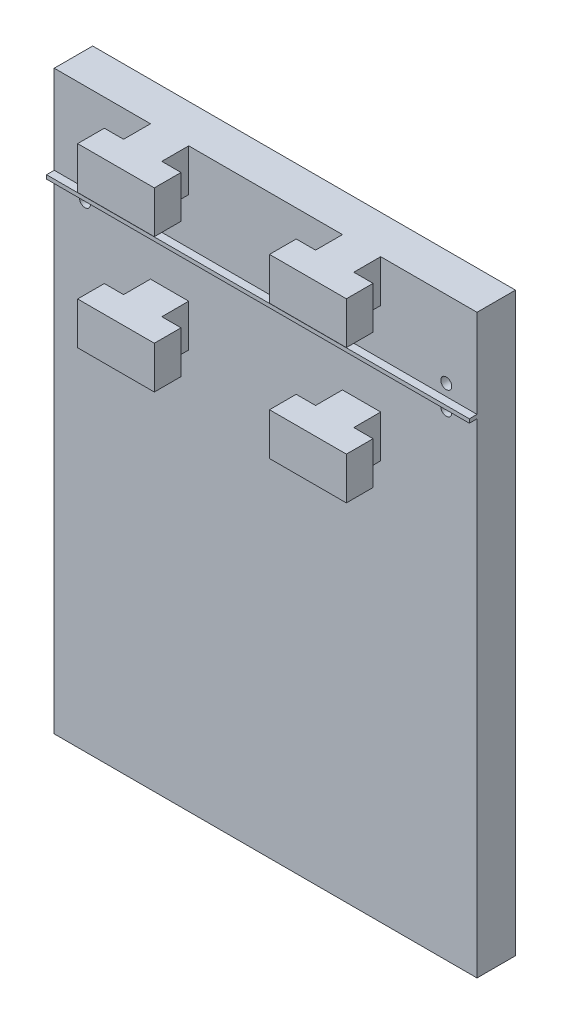
from build123d import *

# Parameters (mm, degrees)
SKETCH1_W           = 110
SKETCH1_H           = 150
BOSS_EXTRUDE1_DEPTH = 10
SKETCH2_W           = 9.95
SKETCH2_H           = 11
BOSS_EXTRUDE2_DEPTH = 7
SKETCH3_W           = 19.95
SKETCH3_H           = 11
SKETCH3_W_2         = 20
BOSS_EXTRUDE3_DEPTH = 6.95
SKETCH6_R           = 1.425
CUT_EXTRUDE1_DEPTH  = 10
SKETCH7_W           = 110
SKETCH7_H           = 1
BOSS_EXTRUDE4_DEPTH = 2


with BuildPart() as part:
    # Sketch1 → Boss-Extrude1 (new body)
    with BuildSketch(Plane.XY):
        with Locations((-38.267930395, -69.615981522)):
            Rectangle(SKETCH1_W, SKETCH1_H)
    extrude(amount=BOSS_EXTRUDE1_DEPTH)

    # Sketch2 → Boss-Extrude2 (add)
    with BuildSketch(Plane.XY.offset(10)):
        with Locations((-63.252930395, -0.115981522)):
            Rectangle(SKETCH2_W, SKETCH2_H)
        with Locations((-13.302930395, -0.115981522)):
            Rectangle(SKETCH2_W, SKETCH2_H)
    boss_extrude2 = extrude(amount=BOSS_EXTRUDE2_DEPTH)

    # Sketch3 → Boss-Extrude3 (add)
    with BuildSketch(Plane.XY.offset(17)):
        with Locations((-63.252930395, -0.115981522)):
            Rectangle(SKETCH3_W, SKETCH3_H)
        with Locations((-13.307930395, -0.115981522)):
            Rectangle(SKETCH3_W_2, SKETCH3_H)
    boss_extrude3 = extrude(amount=BOSS_EXTRUDE3_DEPTH)

    # Sketch6 → Cut-Extrude1 (cut)
    with BuildSketch(Plane.XY.offset(10)):
        with Locations((-85.267930395, -20.615981522)):
            Circle(SKETCH6_R)
        with Locations((8.732069605, -20.615981522)):
            Circle(SKETCH6_R)
    cut_extrude1 = extrude(amount=-CUT_EXTRUDE1_DEPTH, mode=Mode.SUBTRACT)

    # Sketch7 → Boss-Extrude4 (add)
    with BuildSketch(Plane.XY.offset(10)):
        with Locations((-38.267930395, -18.115981522)):
            Rectangle(SKETCH7_W, SKETCH7_H)
    extrude(amount=BOSS_EXTRUDE4_DEPTH)

    # Mirror1: Boss-Extrude2, Boss-Extrude3, Cut-Extrude1 across plane
    add(boss_extrude2.mirror(Plane(origin=(16.732069605, -17.615981522, 12), x_dir=(0, 0, 1), z_dir=(0, -1, 0))))
    add(boss_extrude3.mirror(Plane(origin=(16.732069605, -17.615981522, 12), x_dir=(0, 0, 1), z_dir=(0, -1, 0))))
    add(cut_extrude1.mirror(Plane(origin=(16.732069605, -17.615981522, 12), x_dir=(0, 0, 1), z_dir=(0, -1, 0))), mode=Mode.SUBTRACT)


solid = part.part
